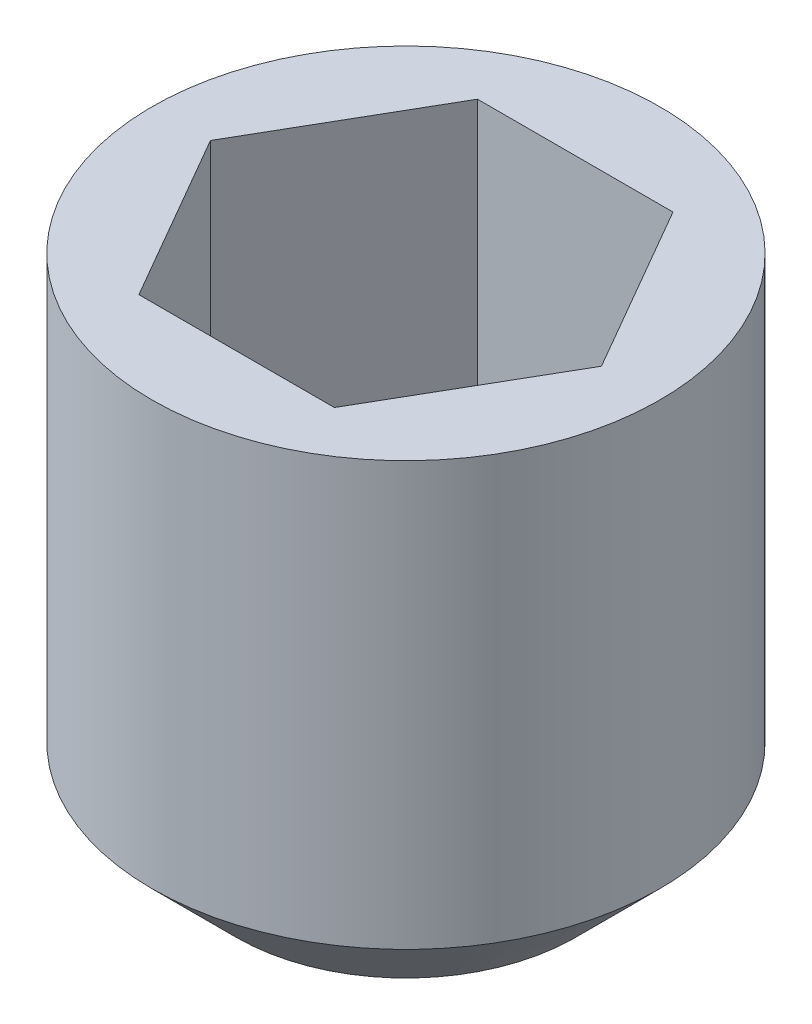
from build123d import *

# Parameters (mm, degrees)
SKETCH1_R           = 1.5
BOSS_EXTRUDE1_DEPTH = 3
CHAMFER1_SIZE       = 0.5
CUT_EXTRUDE1_DEPTH  = 1.5


with BuildPart() as part:
    # Sketch1 → Boss-Extrude1 (new body)
    with BuildSketch(Plane(origin=(0, 0, 0), x_dir=(1, 0, 0), z_dir=(0, 1, 0))):
        Circle(SKETCH1_R)
    extrude(amount=BOSS_EXTRUDE1_DEPTH)

    # Chamfer1
    chamfer1_edges = [part.edges().sort_by_distance(p)[0] for p in [
        (-1.5, 0, 0),
    ]]
    chamfer(chamfer1_edges, length=CHAMFER1_SIZE)

    # Sketch2 → Cut-Extrude1 (cut)
    with BuildSketch(Plane(origin=(0, 3, 0), x_dir=(1, 0, 0), z_dir=(0, 1, 0))):
        Polygon((0.577350269, -1), (1.154700538, 0), (0.577350269, 1), (-0.577350269, 1), (-1.154700538, 0), (-0.577350269, -1), align=None)
    extrude(amount=-CUT_EXTRUDE1_DEPTH, mode=Mode.SUBTRACT)


solid = part.part
